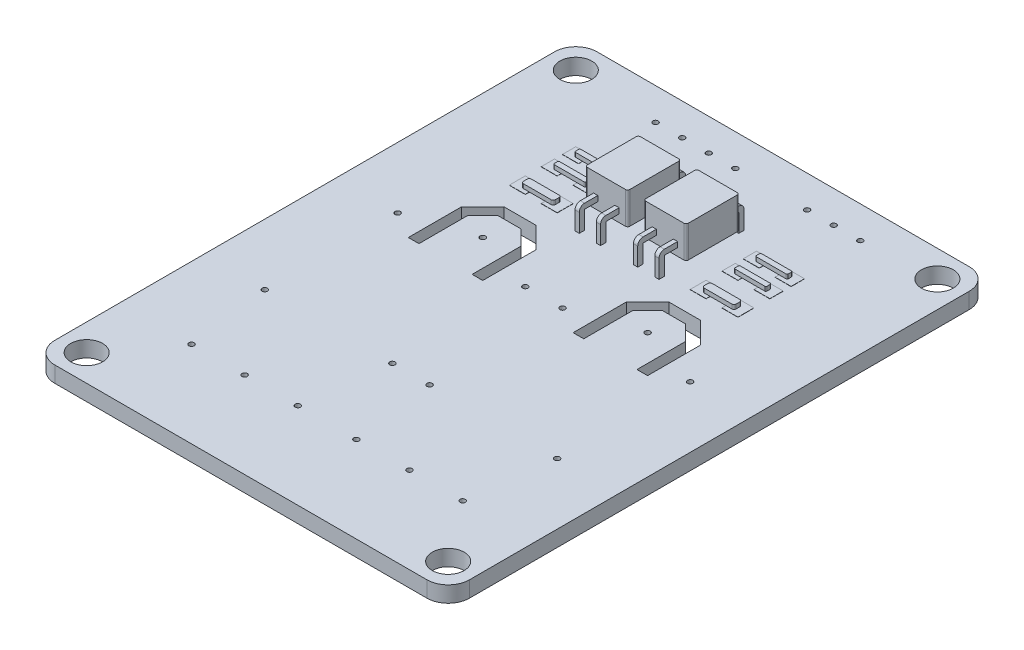
from build123d import *

# Parameters (mm, degrees)
IZIM1_R                          = 1.5
IZIM1_R_2                        = 0.25
Y_KSEKLIK_EKSTR_ZYON1_DEPTH      = 1.5
IZIM2_W                          = 1.5
IZIM2_H                          = 1.5
IZIM2_H_2                        = 1.25
Y_KSEKLIK_EKSTR_ZYON2_DEPTH      = 0.02
Y_KSEKLIK_EKSTR_ZYON3_DEPTH      = 0.4
Y_KSEKLIK_EKSTR_ZYON4_DEPTH      = 3
Y_KSEKLIK_EKSTR_ZYON4_2_DEPTH    = 3
Y_KSEKLIK_EKSTR_ZYON5_DEPTH      = 0.2
Y_KSEKLIK_EKSTR_ZYON5_DEPTH_BACK = 0.2
Y_KSEKLIK_EKSTR_ZYON6_DEPTH      = 0.2
Y_KSEKLIK_EKSTR_ZYON6_DEPTH_BACK = 0.2
Y_KSEKLIK_EKSTR_ZYON7_DEPTH      = 0.2
Y_KSEKLIK_EKSTR_ZYON7_DEPTH_BACK = 0.2
Y_KSEKLIK_EKSTR_ZYON8_DEPTH      = 0.2
Y_KSEKLIK_EKSTR_ZYON8_DEPTH_BACK = 0.2


with BuildPart() as part:
    # Çizim1 → Yükseklik-Ekstrüzyon1 (new body)
    with BuildSketch(Plane(origin=(0, 0, 0), x_dir=(1, 0, 0), z_dir=(0, 1, 0))):
        with BuildLine():
            Line((-17.5, 25.5), (17.5, 25.5))
            ThreePointArc((17.5, 25.5), (18.914213562, 24.914213562), (19.5, 23.5))
            Line((19.5, 23.5), (19.5, -23.5))
            ThreePointArc((19.5, -23.5), (18.914213562, -24.914213562), (17.5, -25.5))
            Line((17.5, -25.5), (-17.5, -25.5))
            ThreePointArc((-17.5, -25.5), (-18.914213562, -24.914213562), (-19.5, -23.5))
            Line((-19.5, -23.5), (-19.5, 23.5))
            ThreePointArc((-19.5, 23.5), (-18.914213562, 24.914213562), (-17.5, 25.5))
        make_face()
        with Locations((-17, 23)):
            Circle(IZIM1_R, mode=Mode.SUBTRACT)
        with Locations((17, 23)):
            Circle(IZIM1_R, mode=Mode.SUBTRACT)
        with Locations((17, -23)):
            Circle(IZIM1_R, mode=Mode.SUBTRACT)
        with Locations((-17, -23)):
            Circle(IZIM1_R, mode=Mode.SUBTRACT)
        with Locations((-13.75, -9.5)):
            Circle(IZIM1_R_2, mode=Mode.SUBTRACT)
        with Locations((-1.75, -9.5)):
            Circle(IZIM1_R_2, mode=Mode.SUBTRACT)
        with Locations((-13.75, 3)):
            Circle(IZIM1_R_2, mode=Mode.SUBTRACT)
        with Locations((-7.75, 5)):
            Circle(IZIM1_R_2, mode=Mode.SUBTRACT)
        with Locations((-1.75, 3)):
            Circle(IZIM1_R_2, mode=Mode.SUBTRACT)
        with Locations((13.75, 3)):
            Circle(IZIM1_R_2, mode=Mode.SUBTRACT)
        with Locations((7.75, 5)):
            Circle(IZIM1_R_2, mode=Mode.SUBTRACT)
        with Locations((1.75, 3)):
            Circle(IZIM1_R_2, mode=Mode.SUBTRACT)
        with Locations((1.75, -9.5)):
            Circle(IZIM1_R_2, mode=Mode.SUBTRACT)
        with Locations((13.75, -9.5)):
            Circle(IZIM1_R_2, mode=Mode.SUBTRACT)
        with Locations((-7.75, -17.39)):
            Circle(IZIM1_R_2, mode=Mode.SUBTRACT)
        with Locations((-2.75, -17.39)):
            Circle(IZIM1_R_2, mode=Mode.SUBTRACT)
        with Locations((-12.75, -17.39)):
            Circle(IZIM1_R_2, mode=Mode.SUBTRACT)
        with Locations((2.75, -17.39)):
            Circle(IZIM1_R_2, mode=Mode.SUBTRACT)
        with Locations((7.75, -17.39)):
            Circle(IZIM1_R_2, mode=Mode.SUBTRACT)
        with Locations((12.75, -17.39)):
            Circle(IZIM1_R_2, mode=Mode.SUBTRACT)
        with Locations((-1.5, 22.5)):
            Circle(IZIM1_R_2, mode=Mode.SUBTRACT)
        with Locations((-4, 22.5)):
            Circle(IZIM1_R_2, mode=Mode.SUBTRACT)
        with Locations((-6.5, 22.5)):
            Circle(IZIM1_R_2, mode=Mode.SUBTRACT)
        with Locations((-9, 22.5)):
            Circle(IZIM1_R_2, mode=Mode.SUBTRACT)
        with Locations((7.75, 22.5)):
            Circle(IZIM1_R_2, mode=Mode.SUBTRACT)
        with Locations((10.25, 22.5)):
            Circle(IZIM1_R_2, mode=Mode.SUBTRACT)
        with Locations((5.25, 22.5)):
            Circle(IZIM1_R_2, mode=Mode.SUBTRACT)
        Polygon((-11.25, 6.5), (-9.25, 8.5), (-6.25, 8.5), (-4.25, 6.5), (-4.25, 1.5), (-5.25, 1.5), (-5.25, 6.085786438), (-6.664213562, 7.5), (-8.835786438, 7.5), (-10.25, 6.085786438), (-10.25, 1.5), (-11.25, 1.5), align=None, mode=Mode.SUBTRACT)
        Polygon((5.25, 1.5), (4.25, 1.5), (4.25, 6.5), (6.25, 8.5), (9.25, 8.5), (11.25, 6.5), (11.25, 1.5), (10.25, 1.5), (10.25, 6.085786438), (8.835786438, 7.5), (6.664213562, 7.5), (5.25, 6.085786438), align=None, mode=Mode.SUBTRACT)
    extrude(amount=Y_KSEKLIK_EKSTR_ZYON1_DEPTH)

    # Çizim2 → Yükseklik-Ekstrüzyon2 (add)
    with BuildSketch(Plane(origin=(0, 1.5, 0), x_dir=(1, 0, 0), z_dir=(0, 1, 0))):
        with Locations((7, 11.25)):
            Rectangle(IZIM2_W, IZIM2_H)
        with Locations((-7, 11.25)):
            Rectangle(IZIM2_W, IZIM2_H)
        with Locations((-10, 11.25)):
            Rectangle(IZIM2_W, IZIM2_H)
        with Locations((-7, 14.125)):
            Rectangle(IZIM2_W, IZIM2_H_2)
        with Locations((-10, 14.125)):
            Rectangle(IZIM2_W, IZIM2_H_2)
        with Locations((-7, 16.125)):
            Rectangle(IZIM2_W, IZIM2_H_2)
        with Locations((-10, 16.125)):
            Rectangle(IZIM2_W, IZIM2_H_2)
        with Locations((10, 11.25)):
            Rectangle(IZIM2_W, IZIM2_H)
        with Locations((7, 14.125)):
            Rectangle(IZIM2_W, IZIM2_H_2)
        with Locations((10, 14.125)):
            Rectangle(IZIM2_W, IZIM2_H_2)
        with Locations((7, 16.125)):
            Rectangle(IZIM2_W, IZIM2_H_2)
        with Locations((10, 16.125)):
            Rectangle(IZIM2_W, IZIM2_H_2)
    extrude(amount=Y_KSEKLIK_EKSTR_ZYON2_DEPTH)

    # Çizim3 → Yükseklik-Ekstrüzyon3 (add)
    with BuildSketch(Plane(origin=(0, 1.52, 0), x_dir=(1, 0, 0), z_dir=(0, 1, 0))):
        with BuildLine():
            Line((-9.9, 16.375), (-7.1, 16.375))
            ThreePointArc((-7.1, 16.375), (-7.029289322, 16.345710678), (-7, 16.275))
            Line((-7, 16.275), (-7, 15.975))
            ThreePointArc((-7, 15.975), (-7.029289322, 15.904289322), (-7.1, 15.875))
            Line((-7.1, 15.875), (-9.9, 15.875))
            ThreePointArc((-9.9, 15.875), (-9.970710678, 15.904289322), (-10, 15.975))
            Line((-10, 15.975), (-10, 16.275))
            ThreePointArc((-10, 16.275), (-9.970710678, 16.345710678), (-9.9, 16.375))
        make_face()
        with BuildLine():
            Line((-9.9, 14.375), (-7.1, 14.375))
            ThreePointArc((-7.1, 14.375), (-7.029289322, 14.345710678), (-7, 14.275))
            Line((-7, 14.275), (-7, 13.975))
            ThreePointArc((-7, 13.975), (-7.029289322, 13.904289322), (-7.1, 13.875))
            Line((-7.1, 13.875), (-9.9, 13.875))
            ThreePointArc((-9.9, 13.875), (-9.970710678, 13.904289322), (-10, 13.975))
            Line((-10, 13.975), (-10, 14.275))
            ThreePointArc((-10, 14.275), (-9.970710678, 14.345710678), (-9.9, 14.375))
        make_face()
        with BuildLine():
            Line((-9.8, 11.625), (-7.2, 11.625))
            ThreePointArc((-7.2, 11.625), (-7.058578644, 11.566421356), (-7, 11.425))
            Line((-7, 11.425), (-7, 11.075))
            ThreePointArc((-7, 11.075), (-7.058578644, 10.933578644), (-7.2, 10.875))
            Line((-7.2, 10.875), (-9.8, 10.875))
            ThreePointArc((-9.8, 10.875), (-9.941421356, 10.933578644), (-10, 11.075))
            Line((-10, 11.075), (-10, 11.425))
            ThreePointArc((-10, 11.425), (-9.941421356, 11.566421356), (-9.8, 11.625))
        make_face()
        with BuildLine():
            Line((9.9, 15.875), (7.1, 15.875))
            ThreePointArc((7.1, 15.875), (7.029289322, 15.904289322), (7, 15.975))
            Line((7, 15.975), (7, 16.275))
            ThreePointArc((7, 16.275), (7.029289322, 16.345710678), (7.1, 16.375))
            Line((7.1, 16.375), (9.9, 16.375))
            ThreePointArc((9.9, 16.375), (9.970710678, 16.345710678), (10, 16.275))
            Line((10, 16.275), (10, 15.975))
            ThreePointArc((10, 15.975), (9.970710678, 15.904289322), (9.9, 15.875))
        make_face()
        with BuildLine():
            Line((9.9, 13.875), (7.1, 13.875))
            ThreePointArc((7.1, 13.875), (7.029289322, 13.904289322), (7, 13.975))
            Line((7, 13.975), (7, 14.275))
            ThreePointArc((7, 14.275), (7.029289322, 14.345710678), (7.1, 14.375))
            Line((7.1, 14.375), (9.9, 14.375))
            ThreePointArc((9.9, 14.375), (9.970710678, 14.345710678), (10, 14.275))
            Line((10, 14.275), (10, 13.975))
            ThreePointArc((10, 13.975), (9.970710678, 13.904289322), (9.9, 13.875))
        make_face()
        with BuildLine():
            Line((9.8, 10.875), (7.2, 10.875))
            ThreePointArc((7.2, 10.875), (7.058578644, 10.933578644), (7, 11.075))
            Line((7, 11.075), (7, 11.425))
            ThreePointArc((7, 11.425), (7.058578644, 11.566421356), (7.2, 11.625))
            Line((7.2, 11.625), (9.8, 11.625))
            ThreePointArc((9.8, 11.625), (9.941421356, 11.566421356), (10, 11.425))
            Line((10, 11.425), (10, 11.075))
            ThreePointArc((10, 11.075), (9.941421356, 10.933578644), (9.8, 10.875))
        make_face()
    extrude(amount=Y_KSEKLIK_EKSTR_ZYON3_DEPTH)



with BuildPart() as body_2:
    # Çizim5 → Yükseklik-Ekstrüzyon4 (new body)
    with BuildSketch(Plane(origin=(0, 2.5, 0), x_dir=(1, 0, 0), z_dir=(0, 1, 0))):
        with BuildLine():
            Line((4.55, 11.625), (0.95, 11.625))
            ThreePointArc((0.95, 11.625), (0.808578644, 11.683578644), (0.75, 11.825))
            Line((0.75, 11.825), (0.75, 16.425))
            ThreePointArc((0.75, 16.425), (0.808578644, 16.566421356), (0.95, 16.625))
            Line((0.95, 16.625), (4.55, 16.625))
            ThreePointArc((4.55, 16.625), (4.691421356, 16.566421356), (4.75, 16.425))
            Line((4.75, 16.425), (4.75, 11.825))
            ThreePointArc((4.75, 11.825), (4.691421356, 11.683578644), (4.55, 11.625))
        make_face()
    extrude(amount=Y_KSEKLIK_EKSTR_ZYON4_DEPTH)


with BuildPart() as body_3:
    # Çizim5 → Y_kseklik-Ekstr_zyon4 2 (new body)
    with BuildSketch(Plane(origin=(0, 2.5, 0), x_dir=(1, 0, 0), z_dir=(0, 1, 0))):
        with BuildLine():
            Line((-4.55, 16.625), (-0.95, 16.625))
            ThreePointArc((-0.95, 16.625), (-0.808578644, 16.566421356), (-0.75, 16.425))
            Line((-0.75, 16.425), (-0.75, 11.825))
            ThreePointArc((-0.75, 11.825), (-0.808578644, 11.683578644), (-0.95, 11.625))
            Line((-0.95, 11.625), (-4.55, 11.625))
            ThreePointArc((-4.55, 11.625), (-4.691421356, 11.683578644), (-4.75, 11.825))
            Line((-4.75, 11.825), (-4.75, 16.425))
            ThreePointArc((-4.75, 16.425), (-4.691421356, 16.566421356), (-4.55, 16.625))
        make_face()
    extrude(amount=Y_KSEKLIK_EKSTR_ZYON4_2_DEPTH)


with BuildPart() as part_1:
    add(part.part)

    add(body_3.part)  # Yükseklik-Ekstrüzyon5 merges body 3
    # Çizim8 → Yükseklik-Ekstrüzyon5 (add, two sides)
    with BuildSketch(Plane.ZY.offset(3.75)) as y_kseklik_ekstr_zyon5_sk:
        with BuildLine():
            Line((-17.375, 3.210871737), (-10.375, 3.210871737))
            Line((-10.375, 3.210871737), (-10.375, 0.798774868))
            Line((-10.375, 0.798774868), (-9.875, 0.798774868))
            Line((-9.875, 0.798774868), (-9.875, 3.210871737))
            ThreePointArc((-9.875, 3.210871737), (-10.021446609, 3.564425128), (-10.375, 3.710871737))
            Line((-10.375, 3.710871737), (-17.375, 3.710871737))
            ThreePointArc((-17.375, 3.710871737), (-17.728553391, 3.564425128), (-17.875, 3.210871737))
            Line((-17.875, 3.210871737), (-17.875, 0.798774868))
            Line((-17.875, 0.798774868), (-17.375, 0.798774868))
            Line((-17.375, 0.798774868), (-17.375, 3.210871737))
        make_face()
    extrude(amount=Y_KSEKLIK_EKSTR_ZYON5_DEPTH)
    extrude(y_kseklik_ekstr_zyon5_sk.sketch, amount=-Y_KSEKLIK_EKSTR_ZYON5_DEPTH_BACK)

    # Çizim9 → Yükseklik-Ekstrüzyon6 (add, two sides)
    with BuildSketch(Plane(origin=(-1.75, 0, 0), x_dir=(0, 0, -1), z_dir=(1, 0, 0))) as y_kseklik_ekstr_zyon6_sk:
        with BuildLine():
            Line((10.378377538, 0.559357084), (10.378377538, 3.210871737))
            Line((10.378377538, 3.210871737), (17.371622462, 3.210871737))
            Line((17.371622462, 3.210871737), (17.371622462, 0.559357084))
            Line((17.371622462, 0.559357084), (17.871622462, 0.559357084))
            Line((17.871622462, 0.559357084), (17.871622462, 3.210871737))
            ThreePointArc((17.871622462, 3.210871737), (17.725175853, 3.564425128), (17.371622462, 3.710871737))
            Line((17.371622462, 3.710871737), (10.378377538, 3.710871737))
            ThreePointArc((10.378377538, 3.710871737), (10.024824147, 3.564425128), (9.878377538, 3.210871737))
            Line((9.878377538, 3.210871737), (9.878377538, 0.559357084))
            Line((9.878377538, 0.559357084), (10.378377538, 0.559357084))
        make_face()
    extrude(amount=Y_KSEKLIK_EKSTR_ZYON6_DEPTH)
    extrude(y_kseklik_ekstr_zyon6_sk.sketch, amount=-Y_KSEKLIK_EKSTR_ZYON6_DEPTH_BACK)


    add(body_2.part)  # Yükseklik-Ekstrüzyon7 merges body 2
    # Çizim10 → Yükseklik-Ekstrüzyon7 (add, two sides)
    with BuildSketch(Plane(origin=(3.75, 0, 0), x_dir=(0, 0, -1), z_dir=(1, 0, 0))) as y_kseklik_ekstr_zyon7_sk:
        with BuildLine():
            Line((10.375, 0.625240508), (10.375, 3.2127649))
            Line((10.375, 3.2127649), (17.375, 3.2127649))
            Line((17.375, 3.2127649), (17.375, 0.625240508))
            Line((17.375, 0.625240508), (17.875, 0.625240508))
            Line((17.875, 0.625240508), (17.875, 3.2127649))
            ThreePointArc((17.875, 3.2127649), (17.728553391, 3.56631829), (17.375, 3.7127649))
            Line((17.375, 3.7127649), (10.375, 3.7127649))
            ThreePointArc((10.375, 3.7127649), (10.021446609, 3.56631829), (9.875, 3.2127649))
            Line((9.875, 3.2127649), (9.875, 0.625240508))
            Line((9.875, 0.625240508), (10.375, 0.625240508))
        make_face()
    extrude(amount=Y_KSEKLIK_EKSTR_ZYON7_DEPTH)
    extrude(y_kseklik_ekstr_zyon7_sk.sketch, amount=-Y_KSEKLIK_EKSTR_ZYON7_DEPTH_BACK)

    # Çizim11 → Yükseklik-Ekstrüzyon8 (add, two sides)
    with BuildSketch(Plane.ZY.offset(-1.75)) as y_kseklik_ekstr_zyon8_sk:
        with BuildLine():
            Line((-17.375, 0.555982075), (-17.375, 3.210871737))
            Line((-17.375, 3.210871737), (-10.375, 3.210871737))
            Line((-10.375, 3.210871737), (-10.375, 0.555982075))
            Line((-10.375, 0.555982075), (-9.875, 0.555982075))
            Line((-9.875, 0.555982075), (-9.875, 3.210871737))
            ThreePointArc((-9.875, 3.210871737), (-10.021446609, 3.564425128), (-10.375, 3.710871737))
            Line((-10.375, 3.710871737), (-17.375, 3.710871737))
            ThreePointArc((-17.375, 3.710871737), (-17.728553391, 3.564425128), (-17.875, 3.210871737))
            Line((-17.875, 3.210871737), (-17.875, 0.555982075))
            Line((-17.875, 0.555982075), (-17.375, 0.555982075))
        make_face()
    extrude(amount=Y_KSEKLIK_EKSTR_ZYON8_DEPTH)
    extrude(y_kseklik_ekstr_zyon8_sk.sketch, amount=-Y_KSEKLIK_EKSTR_ZYON8_DEPTH_BACK)


solid = part_1.part
